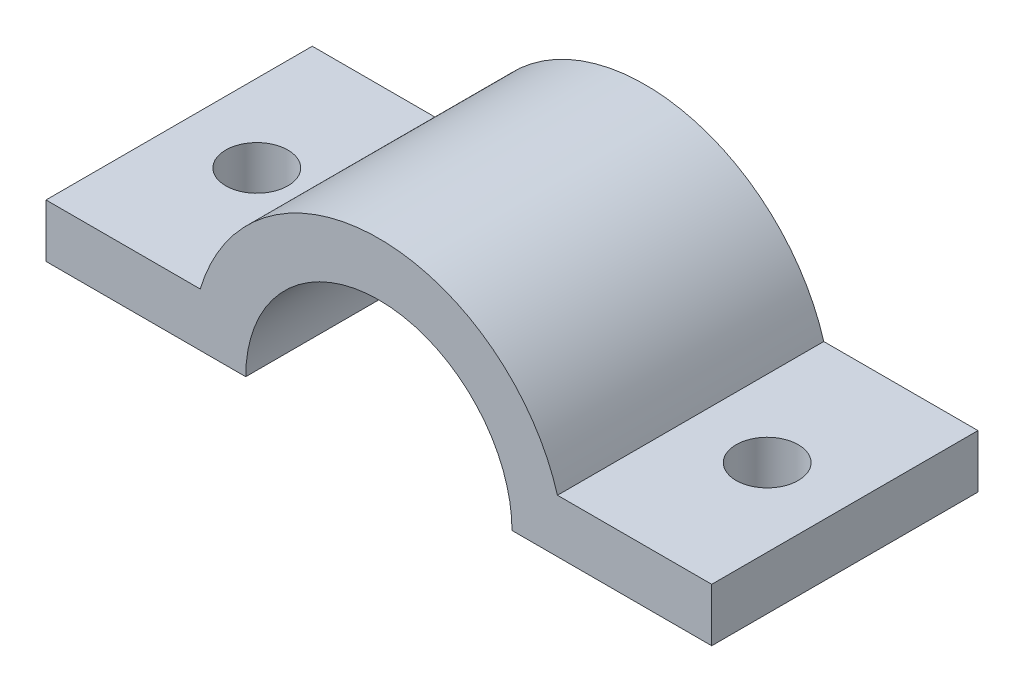
from build123d import *

# Parameters (mm, degrees)
RESSALTO_EXTRUS_O1_DEPTH   = 15
FURO_DE_DI_METRO_7_0_7_1_D = 7


with BuildPart() as part:
    # Esboço1 → Ressalto-extrusão1 (new body, symmetric)
    with BuildSketch(Plane.XY):
        with BuildLine():
            Line((15, 0), (37.5, 0))
            Line((37.5, 0), (37.5, 6))
            Line((37.5, 6), (20.124611797, 6))
            ThreePointArc((20.124611797, 6), (0, 21), (-20.124611797, 6))
            Line((-20.124611797, 6), (-37.5, 6))
            Line((-37.5, 6), (-37.5, 0))
            Line((-37.5, 0), (-15, 0))
            ThreePointArc((-15, 0), (0, 15), (15, 0))
        make_face()
    extrude(amount=RESSALTO_EXTRUS_O1_DEPTH, both=True)

    # Furo de diâmetro Ø7.0 (7)1 (through all)
    with Locations(Plane(origin=(0, 6, 0), x_dir=(1, 0, 0), z_dir=(0, 1, 0))):
        with Locations((-28.75, 0), (28.75, 0)):
            Hole(FURO_DE_DI_METRO_7_0_7_1_D / 2)


solid = part.part
